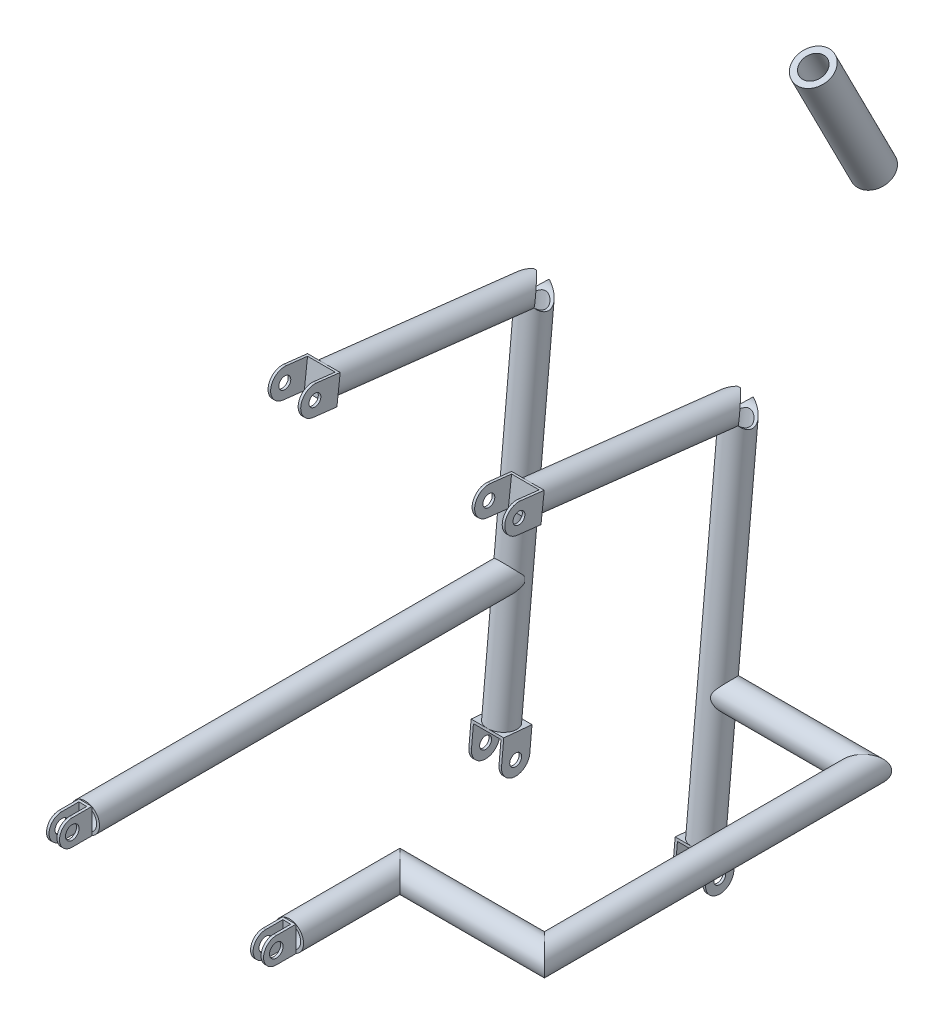
from build123d import *

# Parameters (mm, degrees)
CROQUIS3_R                   = 7
SALIENTE_EXTRUIR1_DEPTH      = 3
SALIENTE_EXTRUIR1_2_DEPTH    = 3
SALIENTE_EXTRUIR2_DEPTH      = 38.4
CROQUIS5_R                   = 7
SALIENTE_EXTRUIR3_DEPTH      = 3
MATRIZL1_COUNT               = 2
MATRIZL1_PITCH               = 240
CROQUIS8_R                   = 8
SALIENTE_EXTRUIR5_DEPTH      = 3
CROQUIS9_W                   = 3
CROQUIS9_H                   = 30
SALIENTE_EXTRUIR6_DEPTH      = 15.3
CROQUIS10_R                  = 8
SALIENTE_EXTRUIR7_DEPTH      = 3
MATRIZL2_COUNT               = 2
MATRIZL2_PITCH               = 240
MATRIZL3_COUNT               = 2
MATRIZL3_PITCH               = 240
SKETCH1_R                    = 16.7005
SKETCH1_R_2                  = 13.3223
MIEMBRO_ESTRUCTURAL2_DEPTH   = 154.618073598
SKETCH1_ON_SEGMENT_2_R       = 16.7005
SKETCH1_ON_SEGMENT_2_R_2     = 13.3223
MIEMBRO_ESTRUCTURAL2_2_DEPTH = 219.236147197
SKETCH1_ON_SEGMENT_3_R       = 16.7005
SKETCH1_ON_SEGMENT_3_R_2     = 13.3223
MIEMBRO_ESTRUCTURAL2_3_DEPTH = 424.236147197
SKETCH1_ON_SEGMENT_4_R       = 16.7005
SKETCH1_ON_SEGMENT_4_R_2     = 13.3223
MIEMBRO_ESTRUCTURAL2_4_DEPTH = 189.968073598
SKETCH11_R                   = 16.7005
SKETCH11_R_2                 = 13.3223
MIEMBRO_ESTRUCTURAL3_DEPTH   = 500
CROQUIS16_R                  = 21.045
CROQUIS16_R_2                = 13.855
SALIENTE_EXTRUIR8_DEPTH      = 100
SALIENTE_EXTRUIR8_DEPTH_BACK = 56.14
CROQUIS17_R                  = 16.7
CORTAR_EXTRUIR1_DEPTH        = 316.14
CROQUIS18_R                  = 16.7
CROQUIS18_R_2                = 13.32
SALIENTE_EXTRUIR9_DEPTH      = 426.14
SALIENTE_EXTRUIR9_2_DEPTH    = 426.14
CROQUIS20_R                  = 16.7
CORTAR_EXTRUIR2_DEPTH        = 218.07
CROQUIS22_R                  = 16.7
CROQUIS22_R_2                = 13.32
SALIENTE_EXTRUIR11_DEPTH     = 250
SALIENTE_EXTRUIR11_2_DEPTH   = 250
CROQUIS20_3_R                = 16.7
CORTAR_EXTRUIR4_DEPTH        = 140


with BuildPart() as part:
    # Croquis3 → Saliente-Extruir1 (new body)
    with BuildSketch(Plane(origin=(137.7, 0, 0), x_dir=(0, 0, -1), z_dir=(1, 0, 0))):
        with BuildLine():
            Line((-124.959693086, 201.853178114), (-100.123604944, 198.995079823))
            Line((-100.123604944, 198.995079823), (-103.942024262, 165.814066066))
            Line((-103.942024262, 165.814066066), (-128.778112403, 168.672164357))
            ThreePointArc((-128.778112403, 168.672164357), (-143.459409623, 187.171880894), (-124.959693086, 201.853178114))
        make_face()
        with Locations((-126.868902744, 185.262671236)):
            Circle(CROQUIS3_R, mode=Mode.SUBTRACT)
    saliente_extruir1 = extrude(amount=SALIENTE_EXTRUIR1_DEPTH)



with BuildPart() as body_2:
    # Croquis3 → Saliente-Extruir1 2 (new body)
    with BuildSketch(Plane(origin=(137.7, 0, 0), x_dir=(0, 0, -1), z_dir=(1, 0, 0))):
        with BuildLine():
            Line((125.916994978, -300.766125944), (128.228005567, -275.873170514))
            Line((128.228005567, -275.873170514), (94.971017112, -272.785660367))
            Line((94.971017112, -272.785660367), (92.660006523, -297.678615797))
            ThreePointArc((92.660006523, -297.678615797), (107.744745677, -315.850865098), (125.916994978, -300.766125944))
        make_face()
        with Locations((109.28850075, -299.222370871)):
            Circle(CROQUIS3_R, mode=Mode.SUBTRACT)
    saliente_extruir1_2 = extrude(amount=SALIENTE_EXTRUIR1_2_DEPTH)


with BuildPart() as part_1:
    add(part.part)

    add(body_2.part)  # Saliente-Extruir2 merges body 2
    # Croquis4 → Saliente-Extruir2 (add)
    with BuildSketch(Plane(origin=(140.7, 0, 0), x_dir=(0, 0, -1), z_dir=(1, 0, 0))):
        Polygon((128.228005567, -275.873170514), (94.971017112, -272.785660367), (95.248338383, -269.798505715), (128.505326838, -272.886015862), align=None)
        Polygon((-100.123604944, 198.995079823), (-103.942024262, 165.814066066), (-100.961693685, 165.471094271), (-97.143274368, 198.652108028), align=None)
    saliente_extruir2 = extrude(amount=-SALIENTE_EXTRUIR2_DEPTH)

    # Croquis5 → Saliente-Extruir3 (add)
    with BuildSketch(Plane.ZY.offset(-102.3)):
        with BuildLine():
            Line((124.959693086, 201.853178114), (100.123604944, 198.995079823))
            Line((100.123604944, 198.995079823), (103.942024262, 165.814066066))
            Line((103.942024262, 165.814066066), (128.778112403, 168.672164357))
            ThreePointArc((128.778112403, 168.672164357), (143.459409623, 187.171880894), (124.959693086, 201.853178114))
        make_face()
        with Locations(Location((126.868902744, 185.262671236, 0), (0, 0, 180))):
            Circle(CROQUIS5_R, mode=Mode.SUBTRACT)
        with BuildLine():
            Line((-94.971017112, -272.785660367), (-92.660006523, -297.678615797))
            ThreePointArc((-92.660006523, -297.678615797), (-107.744745677, -315.850865098), (-125.916994978, -300.766125944))
            Line((-125.916994978, -300.766125944), (-128.228005567, -275.873170514))
            Line((-128.228005567, -275.873170514), (-94.971017112, -272.785660367))
        make_face()
        with Locations(Location((-109.28850075, -299.222370871, 0), (0, 0, 180))):
            Circle(CROQUIS5_R, mode=Mode.SUBTRACT)
    saliente_extruir3 = extrude(amount=-SALIENTE_EXTRUIR3_DEPTH)


with BuildPart() as matrizl1_1:
    # MatrizL1: Saliente-Extruir1, Saliente-Extruir1 2, Saliente-Extruir2, Saliente-Extruir3 ×2
    with Locations(*[(-i * MATRIZL1_PITCH, 0, 0) for i in range(1, MATRIZL1_COUNT)]):
        add(saliente_extruir1)
        add(saliente_extruir1_2)
        add(saliente_extruir2)
        add(saliente_extruir3)


with BuildPart() as body_3:
    # Croquis8 → Saliente-Extruir5 (new body)
    with BuildSketch(Plane(origin=(126.3, 0, 0), x_dir=(0, 0, -1), z_dir=(1, 0, 0))):
        with BuildLine():
            Line((-380.863168832, -138.728462943), (-400.863168832, -138.728462943))
            ThreePointArc((-400.863168832, -138.728462943), (-415.863168832, -123.728462943), (-400.863168832, -108.728462943))
            Line((-400.863168832, -108.728462943), (-380.863168832, -108.728462943))
            Line((-380.863168832, -108.728462943), (-380.863168832, -138.728462943))
        make_face()
        with Locations((-400.863168832, -123.728462943)):
            Circle(CROQUIS8_R, mode=Mode.SUBTRACT)
    saliente_extruir5 = extrude(amount=SALIENTE_EXTRUIR5_DEPTH)

    # Croquis9 → Saliente-Extruir6 (add)
    with BuildSketch(Plane(origin=(129.3, 0, 0), x_dir=(0, 0, -1), z_dir=(1, 0, 0))):
        with Locations((-379.363168832, -123.728462943)):
            Rectangle(CROQUIS9_W, CROQUIS9_H)
    saliente_extruir6 = extrude(amount=-SALIENTE_EXTRUIR6_DEPTH)

    # Croquis10 → Saliente-Extruir7 (add)
    with BuildSketch(Plane.ZY.offset(-114)):
        with BuildLine():
            Line((380.863168832, -108.728462943), (400.863168832, -108.728462943))
            ThreePointArc((400.863168832, -108.728462943), (415.863168832, -123.728462943), (400.863168832, -138.728462943))
            Line((400.863168832, -138.728462943), (380.863168832, -138.728462943))
            Line((380.863168832, -138.728462943), (380.863168832, -108.728462943))
        make_face()
        with Locations(Location((400.863168832, -123.728462943, 0), (0, 0, 180))):
            Circle(CROQUIS10_R, mode=Mode.SUBTRACT)
    saliente_extruir7 = extrude(amount=-SALIENTE_EXTRUIR7_DEPTH)


with BuildPart() as matrizl2_1:
    # MatrizL2: Saliente-Extruir5, Saliente-Extruir7 ×2
    with Locations(*[(-i * MATRIZL2_PITCH, 0, 0) for i in range(1, MATRIZL2_COUNT)]):
        add(saliente_extruir5)
        add(saliente_extruir7)

    # MatrizL3: Saliente-Extruir6 ×2
    with Locations(*[(-i * MATRIZL3_PITCH, 0, 0) for i in range(1, MATRIZL3_COUNT)]):
        add(saliente_extruir6)


with BuildPart() as body_5:
    # Sketch1 → Miembro estructural2 (new body)
    with BuildSketch(Plane(origin=(121.65, -123.728462943, 377.863168832), x_dir=(-1, 0, 0), z_dir=(0, 0, -1))):
        Circle(SKETCH1_R)
        Circle(SKETCH1_R_2, mode=Mode.SUBTRACT)
    extrude(amount=MIEMBRO_ESTRUCTURAL2_DEPTH)

    # Miembro estructural2 mitre 1
    split(bisect_by=Plane(origin=(121.65, -123.728462943, 247.863168832), x_dir=(0, -1, 0), z_dir=(-0.707106781, 0, 0.707106781)), keep=Keep.TOP)


with BuildPart() as body_6:
    # Sketch1 on segment 2 (carried to segment 2) → Miembro estructural2 2 (new body)
    with BuildSketch(Plane(origin=(97.031926402, -123.728462943, 247.863168832), x_dir=(0, 0, -1), z_dir=(1, 0, 0))):
        Circle(SKETCH1_ON_SEGMENT_2_R)
        Circle(SKETCH1_ON_SEGMENT_2_R_2, mode=Mode.SUBTRACT)
    extrude(amount=MIEMBRO_ESTRUCTURAL2_2_DEPTH)

    # Miembro estructural2 2 mitre 1
    split(bisect_by=Plane(origin=(121.65, -123.728462943, 247.863168832), x_dir=(0, 1, 0), z_dir=(0.707106781, 0, -0.707106781)), keep=Keep.TOP)

    # Miembro estructural2 2 mitre 2
    split(bisect_by=Plane(origin=(291.65, -123.728462943, 247.863168832), x_dir=(0, -1, 0), z_dir=(-0.707106781, 0, 0.707106781)), keep=Keep.TOP)


with BuildPart() as body_7:
    # Sketch1 on segment 3 (carried to segment 3) → Miembro estructural2 3 (new body)
    with BuildSketch(Plane(origin=(291.65, -123.728462943, 272.481242431), x_dir=(-1, 0, 0), z_dir=(0, 0, -1))):
        Circle(SKETCH1_ON_SEGMENT_3_R)
        Circle(SKETCH1_ON_SEGMENT_3_R_2, mode=Mode.SUBTRACT)
    extrude(amount=MIEMBRO_ESTRUCTURAL2_3_DEPTH)

    # Miembro estructural2 3 mitre 1
    split(bisect_by=Plane(origin=(291.65, -123.728462943, 247.863168832), x_dir=(0, 1, 0), z_dir=(0.707106781, 0, -0.707106781)), keep=Keep.TOP)

    # Miembro estructural2 3 mitre 2
    split(bisect_by=Plane(origin=(291.65, -123.728462943, -127.136831168), x_dir=(0, 1, 0), z_dir=(0.707106781, 0, 0.707106781)), keep=Keep.TOP)


with BuildPart() as body_8:
    # Sketch1 on segment 4 (carried to segment 4) → Miembro estructural2 4 (new body)
    with BuildSketch(Plane(origin=(316.268073598, -123.728462943, -127.136831168), x_dir=(0, 0, 1), z_dir=(-1, 0, 0))):
        Circle(SKETCH1_ON_SEGMENT_4_R)
        Circle(SKETCH1_ON_SEGMENT_4_R_2, mode=Mode.SUBTRACT)
    extrude(amount=MIEMBRO_ESTRUCTURAL2_4_DEPTH)

    # Miembro estructural2 4 mitre 1
    split(bisect_by=Plane(origin=(291.65, -123.728462943, -127.136831168), x_dir=(0, -1, 0), z_dir=(-0.707106781, 0, -0.707106781)), keep=Keep.TOP)


with BuildPart() as body_9:
    # Sketch11 → Miembro estructural3 (new body)
    with BuildSketch(Plane(origin=(-118.35, -123.728462943, 377.863168832), x_dir=(-1, 0, 0), z_dir=(0, 0, -1))):
        Circle(SKETCH11_R)
        Circle(SKETCH11_R_2, mode=Mode.SUBTRACT)
    extrude(amount=MIEMBRO_ESTRUCTURAL3_DEPTH)


with BuildPart() as body_10:
    # Croquis16 → Saliente-Extruir8 (new, two sides)
    with BuildSketch(Plane(origin=(0, 280.575552268, -385.489763225), x_dir=(-1, 0, 0), z_dir=(0, -0.891006524188367, -0.45399049973954875))) as saliente_extruir8_sk:
        with Locations(Location((0, 0, 0), (0, 0, 90))):
            Circle(CROQUIS16_R)
        with Locations(Location((0, 0, 0), (0, 0, 90))):
            Circle(CROQUIS16_R_2, mode=Mode.SUBTRACT)
    extrude(amount=SALIENTE_EXTRUIR8_DEPTH)
    extrude(saliente_extruir8_sk.sketch, amount=-SALIENTE_EXTRUIR8_DEPTH_BACK)


with BuildPart() as cortar_extruir1_tool:
    # Croquis17 → Cortar-Extruir1 (new body)
    with BuildSketch(Plane(origin=(0, -258.725918396, 24.019580112), x_dir=(1, 0, 0), z_dir=(0, 0.9957182172123169, -0.09244042357932776))):
        with Locations((-118.5, 136.480793837)):
            Circle(CROQUIS17_R)
        with Locations((121.5, 136.480793837)):
            Circle(CROQUIS17_R)
    extrude(amount=CORTAR_EXTRUIR1_DEPTH)


with BuildPart() as body_8_1:
    add(body_8.part)

    # Cortar-Extruir1: cut by cortar_extruir1_tool
    add(cortar_extruir1_tool.part, mode=Mode.SUBTRACT)


with BuildPart() as body_9_1:
    add(body_9.part)

    # Cortar-Extruir1: cut by cortar_extruir1_tool
    add(cortar_extruir1_tool.part, mode=Mode.SUBTRACT)


with BuildPart() as body_11:
    # Croquis18 → Saliente-Extruir9 (new body)
    with BuildSketch(Plane(origin=(0, -258.725918396, 24.019580112), x_dir=(1, 0, 0), z_dir=(0, 0.9957182172123169, -0.09244042357932776))):
        with Locations(Location((-118.5, 136.480793837, 0), (0, 0, 270))):
            Circle(CROQUIS18_R)
        with Locations(Location((-118.5, 136.480793837, 0), (0, 0, 270))):
            Circle(CROQUIS18_R_2, mode=Mode.SUBTRACT)
    extrude(amount=SALIENTE_EXTRUIR9_DEPTH)


with BuildPart() as body_12:
    # Croquis18 → Saliente-Extruir9 2 (new body)
    with BuildSketch(Plane(origin=(0, -258.725918396, 24.019580112), x_dir=(1, 0, 0), z_dir=(0, 0.9957182172123169, -0.09244042357932776))):
        with Locations(Location((121.5, 136.480793837, 0), (0, 0, 270))):
            Circle(CROQUIS18_R)
        with Locations(Location((121.5, 136.480793837, 0), (0, 0, 270))):
            Circle(CROQUIS18_R_2, mode=Mode.SUBTRACT)
    extrude(amount=SALIENTE_EXTRUIR9_2_DEPTH)


with BuildPart() as cortar_extruir2_tool:
    # Croquis20 → Cortar-Extruir2 (new, symmetric)
    with BuildSketch(Plane(origin=(0, 0, 0), x_dir=(0, 0, -1), z_dir=(1, 0, 0))):
        with Locations((151.295284437, 153.251970371)):
            Circle(CROQUIS20_R)
    extrude(amount=CORTAR_EXTRUIR2_DEPTH, both=True)


with BuildPart() as body_11_1:
    add(body_11.part)

    # Cortar-Extruir2: cut by cortar_extruir2_tool
    add(cortar_extruir2_tool.part, mode=Mode.SUBTRACT)


with BuildPart() as body_12_1:
    add(body_12.part)

    # Cortar-Extruir2: cut by cortar_extruir2_tool
    add(cortar_extruir2_tool.part, mode=Mode.SUBTRACT)


with BuildPart() as body_13:
    # Croquis22 → Saliente-Extruir11 (new body)
    with BuildSketch(Plane(origin=(0, 13.629361534, 118.435403491), x_dir=(-1, 0, 0), z_dir=(0, -0.11432393165858512, -0.9934435256470915))):
        with Locations(Location((-121.5, 169.543849516, 0), (0, 0, 90))):
            Circle(CROQUIS22_R)
        with Locations(Location((-121.5, 169.543849516, 0), (0, 0, 90))):
            Circle(CROQUIS22_R_2, mode=Mode.SUBTRACT)
    extrude(amount=SALIENTE_EXTRUIR11_DEPTH)


with BuildPart() as body_14:
    # Croquis22 → Saliente-Extruir11 2 (new body)
    with BuildSketch(Plane(origin=(0, 13.629361534, 118.435403491), x_dir=(-1, 0, 0), z_dir=(0, -0.11432393165858512, -0.9934435256470915))):
        with Locations(Location((118.5, 169.543849516, 0), (0, 0, 90))):
            Circle(CROQUIS22_R)
        with Locations(Location((118.5, 169.543849516, 0), (0, 0, 90))):
            Circle(CROQUIS22_R_2, mode=Mode.SUBTRACT)
    extrude(amount=SALIENTE_EXTRUIR11_2_DEPTH)


with BuildPart() as cortar_extruir4_tool:
    # Croquis20_3 → Cortar-Extruir4 (new, symmetric)
    with BuildSketch(Plane(origin=(0, 0, 0), x_dir=(0, 0, -1), z_dir=(1, 0, 0))):
        with Locations((151.295284437, 153.251970371)):
            Circle(CROQUIS20_3_R)
    extrude(amount=CORTAR_EXTRUIR4_DEPTH, both=True)


with BuildPart() as body_13_1:
    add(body_13.part)

    # Cortar-Extruir4: cut by cortar_extruir4_tool
    add(cortar_extruir4_tool.part, mode=Mode.SUBTRACT)


with BuildPart() as body_14_1:
    add(body_14.part)

    # Cortar-Extruir4: cut by cortar_extruir4_tool
    add(cortar_extruir4_tool.part, mode=Mode.SUBTRACT)


solid = Compound([part_1.part, matrizl1_1.part, body_3.part, matrizl2_1.part, body_5.part, body_6.part, body_7.part, body_10.part, body_8_1.part, body_9_1.part, body_11_1.part, body_12_1.part, body_13_1.part, body_14_1.part])
